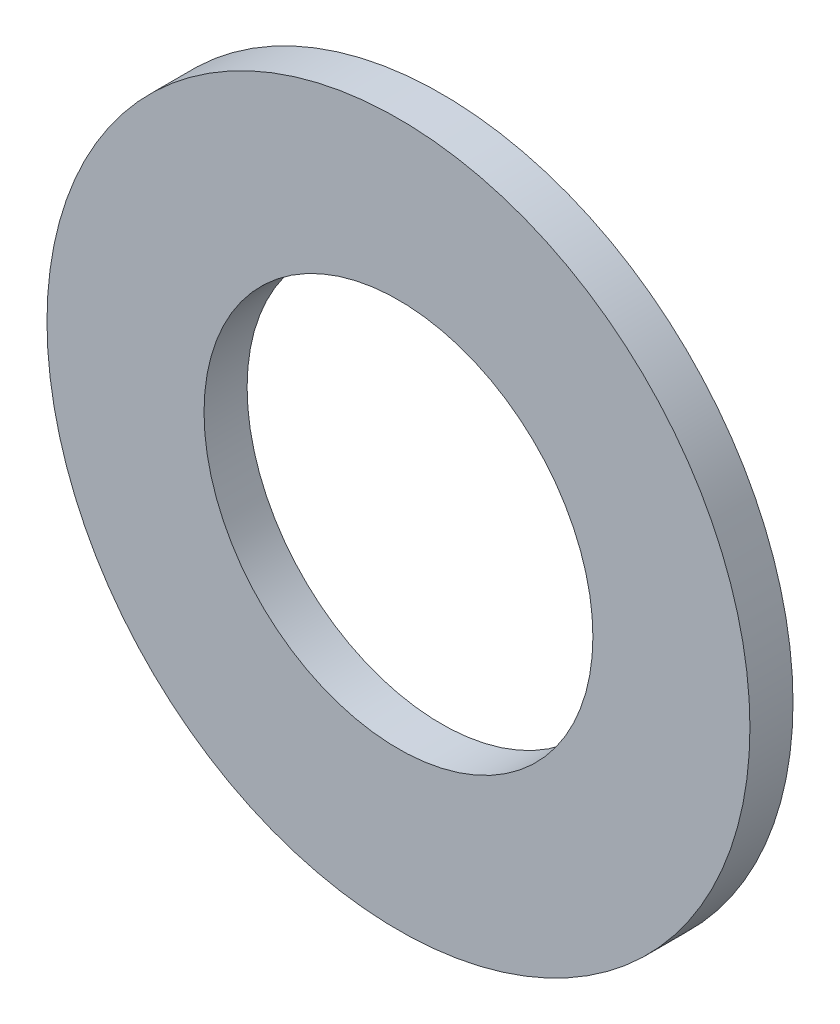
from build123d import *

# Parameters (mm, degrees)
SKETCH1_R      = 18.653125
SKETCH1_R_2    = 10.31875
EXTRUDE1_DEPTH = 2.286


with BuildPart() as part:
    # Sketch1 → Extrude1 (new body)
    with BuildSketch(Plane.XY):
        Circle(SKETCH1_R)
        Circle(SKETCH1_R_2, mode=Mode.SUBTRACT)
    extrude(amount=-EXTRUDE1_DEPTH)


solid = part.part
